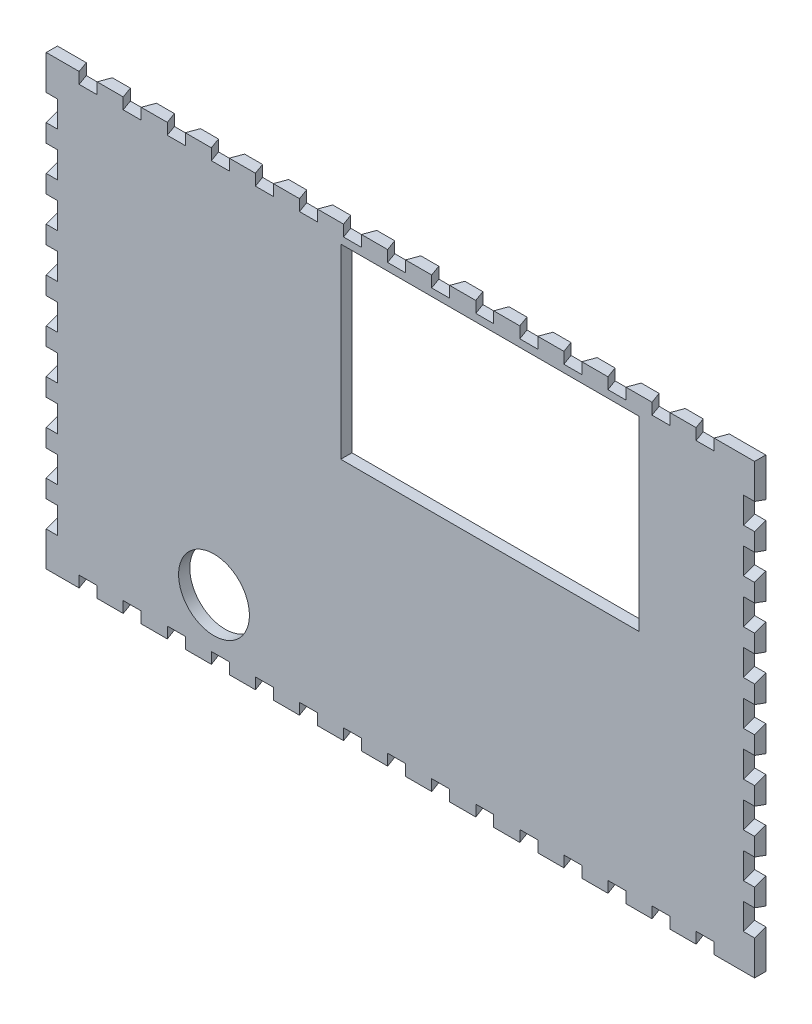
from build123d import *

# Parameters (mm, degrees)
SKETCH1_R           = 9.5
SKETCH1_W           = 80
SKETCH1_H           = 50
BOSS_EXTRUDE1_DEPTH = 3
CUT_EXTRUDE1_DEPTH  = 3
CUT_EXTRUDE3_START  = -117
CUT_EXTRUDE3_DEPTH  = 187
CUT_EXTRUDE5_DEPTH  = 3
CUT_EXTRUDE6_START  = -187
CUT_EXTRUDE6_DEPTH  = 3


with BuildPart() as part:
    # Sketch1 → Boss-Extrude1 (new body)
    with BuildSketch(Plane.XY):
        Polygon((10, 0), (190, 0), (190, 120), (9.862497021, 120), (0, 120), (0, 0), align=None)
        with Locations((45, 16.5)):
            Circle(SKETCH1_R, mode=Mode.SUBTRACT)
        with Locations((119, 90)):
            Rectangle(SKETCH1_W, SKETCH1_H, mode=Mode.SUBTRACT)
    extrude(amount=BOSS_EXTRUDE1_DEPTH)

    # Sketch3 → Cut-Extrude1 (cut)
    with BuildSketch(Plane(origin=(0, 120, 0), x_dir=(1, 0, 0), z_dir=(0, 1, 0))):
        Polygon((179.128089803, -3), (180.22, 0), (173.22, 0), (174.311910703, -3), align=None)
        Polygon((167.308089803, -3), (168.4, 0), (161.4, 0), (162.491910703, -3), align=None)
        Polygon((155.488089803, -3), (156.58, 0), (149.58, 0), (150.671910703, -3), align=None)
        Polygon((143.668089803, -3), (144.76, 0), (137.76, 0), (138.851910703, -3), align=None)
        Polygon((131.848089803, -3), (132.94, 0), (125.94, 0), (127.031910703, -3), align=None)
        Polygon((120.028089803, -3), (121.12, 0), (114.12, 0), (115.211910703, -3), align=None)
        Polygon((108.208089803, -3), (109.3, 0), (102.3, 0), (103.391910703, -3), align=None)
        Polygon((96.388089803, -3), (97.48, 0), (90.48, 0), (91.571910703, -3), align=None)
        Polygon((84.568089803, -3), (85.66, 0), (78.66, 0), (79.751910703, -3), align=None)
        Polygon((72.748089803, -3), (73.84, 0), (66.84, 0), (67.931910703, -3), align=None)
        Polygon((60.928089803, -3), (62.02, 0), (55.02, 0), (56.111910703, -3), align=None)
        Polygon((49.108089803, -3), (50.2, 0), (43.2, 0), (44.291910703, -3), align=None)
        Polygon((37.288089803, -3), (38.38, 0), (31.38, 0), (32.471910703, -3), align=None)
        Polygon((25.468089803, -3), (26.56, 0), (19.56, 0), (20.651910703, -3), align=None)
        Polygon((13.648089803, -3), (14.74, 0), (7.74, 0), (8.831910703, -3), align=None)
    extrude(amount=-CUT_EXTRUDE1_DEPTH, mode=Mode.SUBTRACT)

    # Sketch3_2 → Cut-Extrude3 (cut)
    with BuildSketch(Plane(origin=(0, 120, 0), x_dir=(1, 0, 0), z_dir=(0, 1, 0)).offset(CUT_EXTRUDE3_START)):
        Polygon((179.128089803, -3), (180.22, 0), (173.22, 0), (174.311910703, -3), align=None)
        Polygon((167.308089803, -3), (168.4, 0), (161.4, 0), (162.491910703, -3), align=None)
        Polygon((155.488089803, -3), (156.58, 0), (149.58, 0), (150.671910703, -3), align=None)
        Polygon((143.668089803, -3), (144.76, 0), (137.76, 0), (138.851910703, -3), align=None)
        Polygon((131.848089803, -3), (132.94, 0), (125.94, 0), (127.031910703, -3), align=None)
        Polygon((120.028089803, -3), (121.12, 0), (114.12, 0), (115.211910703, -3), align=None)
        Polygon((108.208089803, -3), (109.3, 0), (102.3, 0), (103.391910703, -3), align=None)
        Polygon((96.388089803, -3), (97.48, 0), (90.48, 0), (91.571910703, -3), align=None)
        Polygon((84.568089803, -3), (85.66, 0), (78.66, 0), (79.751910703, -3), align=None)
        Polygon((72.748089803, -3), (73.84, 0), (66.84, 0), (67.931910703, -3), align=None)
        Polygon((60.928089803, -3), (62.02, 0), (55.02, 0), (56.111910703, -3), align=None)
        Polygon((49.108089803, -3), (50.2, 0), (43.2, 0), (44.291910703, -3), align=None)
        Polygon((37.288089803, -3), (38.38, 0), (31.38, 0), (32.471910703, -3), align=None)
        Polygon((25.468089803, -3), (26.56, 0), (19.56, 0), (20.651910703, -3), align=None)
        Polygon((13.648089803, -3), (14.74, 0), (7.74, 0), (8.831910703, -3), align=None)
    extrude(amount=-CUT_EXTRUDE3_DEPTH, mode=Mode.SUBTRACT)

    # Sketch6 → Cut-Extrude5 (cut)
    with BuildSketch(Plane.ZY):
        Polygon((0, 104.7919109), (3, 103.7), (3, 110.7), (0, 109.60809), align=None)
        Polygon((0, 92.9919109), (3, 91.9), (3, 98.9), (0, 97.80809), align=None)
        Polygon((0, 81.1919109), (3, 80.1), (3, 87.1), (0, 86.00809), align=None)
        Polygon((0, 69.3919109), (3, 68.3), (3, 75.3), (0, 74.20809), align=None)
        Polygon((0, 57.5919109), (3, 56.5), (3, 63.5), (0, 62.40809), align=None)
        Polygon((0, 45.7919109), (3, 44.7), (3, 51.7), (0, 50.60809), align=None)
        Polygon((0, 33.9919109), (3, 32.9), (3, 39.9), (0, 38.80809), align=None)
        Polygon((0, 22.1919109), (3, 21.1), (3, 28.1), (0, 27.00809), align=None)
        Polygon((0, 10.3919109), (3, 9.3), (3, 16.3), (0, 15.20809), align=None)
    extrude(amount=-CUT_EXTRUDE5_DEPTH, mode=Mode.SUBTRACT)

    # Sketch6_3 → Cut-Extrude6 (cut)
    with BuildSketch(Plane.ZY.offset(CUT_EXTRUDE6_START)):
        Polygon((0, 104.7919109), (3, 103.7), (3, 110.7), (0, 109.60809), align=None)
        Polygon((0, 92.9919109), (3, 91.9), (3, 98.9), (0, 97.80809), align=None)
        Polygon((0, 81.1919109), (3, 80.1), (3, 87.1), (0, 86.00809), align=None)
        Polygon((0, 69.3919109), (3, 68.3), (3, 75.3), (0, 74.20809), align=None)
        Polygon((0, 57.5919109), (3, 56.5), (3, 63.5), (0, 62.40809), align=None)
        Polygon((0, 45.7919109), (3, 44.7), (3, 51.7), (0, 50.60809), align=None)
        Polygon((0, 33.9919109), (3, 32.9), (3, 39.9), (0, 38.80809), align=None)
        Polygon((0, 22.1919109), (3, 21.1), (3, 28.1), (0, 27.00809), align=None)
        Polygon((0, 10.3919109), (3, 9.3), (3, 16.3), (0, 15.20809), align=None)
    extrude(amount=-CUT_EXTRUDE6_DEPTH, mode=Mode.SUBTRACT)


solid = part.part
